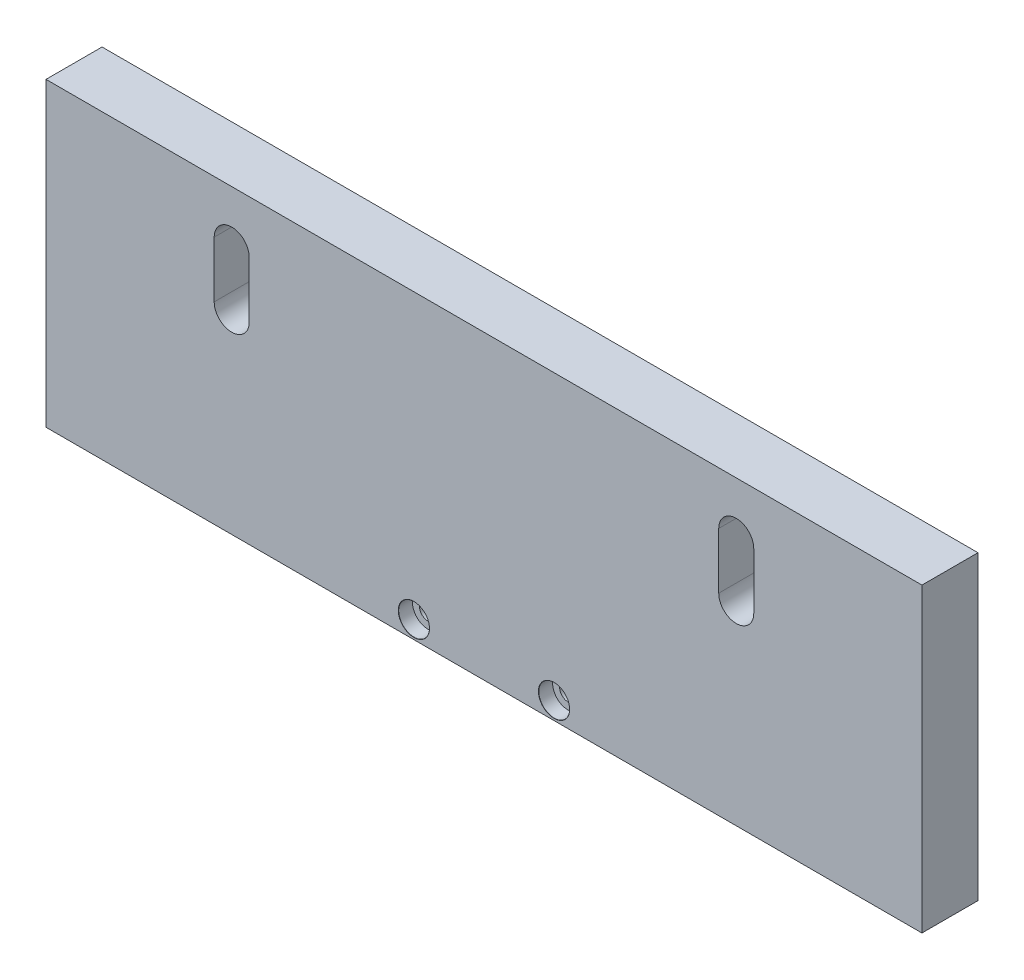
from build123d import *

# Parameters (mm, degrees)
ESBO_O1_W                        = 125
ESBO_O1_H                        = 43
RESSALTO_EXTRUS_O1_DEPTH         = 8
CORTE_EXTRUS_O1_DEPTH            = 9
REBAIXO_PARA_SHCS_M21_AT_2_COUNT = 2
REBAIXO_PARA_SHCS_M21_AT_2_PITCH = 20
ESBO_O6_R                        = 11
CORTE_EXTRUS_O2_DEPTH            = 7


with BuildPart() as part:
    # Esboço1 → Ressalto-extrusão1 (new body)
    with BuildSketch(Plane.XY):
        Rectangle(ESBO_O1_W, ESBO_O1_H)
    extrude(amount=RESSALTO_EXTRUS_O1_DEPTH)

    # Esboço2 → Corte-extrusão1 (cut, through all)
    with BuildSketch(Plane.XY.offset(8)):
        with BuildLine():
            Line((-33.5, 6), (-33.5, 14))
            ThreePointArc((-33.5, 14), (-36, 16.5), (-38.5, 14))
            Line((-38.5, 14), (-38.5, 6))
            ThreePointArc((-38.5, 6), (-36, 3.5), (-33.5, 6))
        make_face()
        with BuildLine():
            Line((38.5, 6), (38.5, 14))
            ThreePointArc((38.5, 14), (36, 16.5), (33.5, 14))
            Line((33.5, 14), (33.5, 6))
            ThreePointArc((33.5, 6), (36, 3.5), (38.5, 6))
        make_face()
    extrude(amount=-CORTE_EXTRUS_O1_DEPTH, mode=Mode.SUBTRACT)

    # Esboço4 → Rebaixo para SHCS M21 (revolve, cut)
    with BuildSketch(Plane(origin=(-10, -19, 8), x_dir=(0, -1, 0), z_dir=(1, 0, 0))):
        Polygon((0, 0), (0, 8), (1.2, 8), (1.2, 2), (2.2, 2), (2.2, 0.025), (2.225, 0), align=None)
    rebaixo_para_shcs_m21 = revolve(axis=Axis((-10, -19, 14.35), (0, 0, -1)), mode=Mode.SUBTRACT)

    # Rebaixo para SHCS M21 at 2: Rebaixo para SHCS M21 ×2
    with Locations(*[(i * REBAIXO_PARA_SHCS_M21_AT_2_PITCH, 0, 0) for i in range(1, REBAIXO_PARA_SHCS_M21_AT_2_COUNT)]):
        add(rebaixo_para_shcs_m21, mode=Mode.SUBTRACT)

    # Esboço6 → Corte-extrusão2 (cut)
    with BuildSketch(Plane(origin=(0, 0, 0), x_dir=(-1, 0, 0), z_dir=(0, 0, -1))):
        with Locations((0, 7)):
            Circle(ESBO_O6_R)
    extrude(amount=-CORTE_EXTRUS_O2_DEPTH, mode=Mode.SUBTRACT)


solid = part.part
